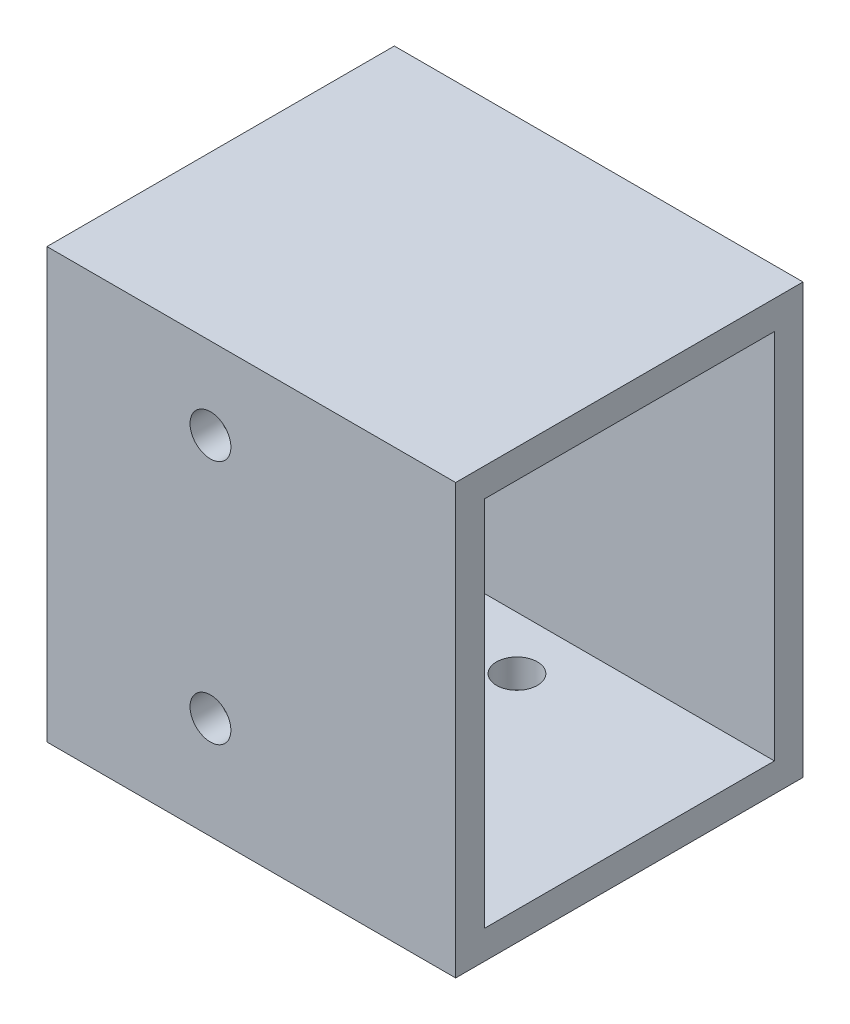
from build123d import *

# Parameters (mm, degrees)
SKETCH1_W                        = 100
SKETCH1_H                        = 85
BOSS_EXTRUDE1_DEPTH              = 105
SKETCH2_W                        = 71
SKETCH2_H                        = 91
CUT_EXTRUDE1_DEPTH               = 90
M10X1_0_TAPPED_HOLE1_D           = 9
M10X1_0_TAPPED_HOLE1_DEPTH       = 23
M10X1_0_TAPPED_HOLE1_CBORE_D     = 10
M10X1_0_TAPPED_HOLE1_CBORE_DEPTH = 20
M10X1_0_TAPPED_HOLE1_TIP         = 2.703872786
M10X1_0_TAPPED_HOLE2_D           = 9
M10X1_0_TAPPED_HOLE2_DEPTH       = 23
M10X1_0_TAPPED_HOLE2_CBORE_D     = 10
M10X1_0_TAPPED_HOLE2_CBORE_DEPTH = 20
M10X1_0_TAPPED_HOLE2_TIP         = 2.703872786
M10X1_0_TAPPED_HOLE3_D           = 9
M10X1_0_TAPPED_HOLE3_DEPTH       = 23
M10X1_0_TAPPED_HOLE3_CBORE_D     = 10
M10X1_0_TAPPED_HOLE3_CBORE_DEPTH = 20
M10X1_0_TAPPED_HOLE3_TIP         = 2.703872786


with BuildPart() as part:
    # Sketch1 → Boss-Extrude1 (new body)
    with BuildSketch(Plane(origin=(0, 0, 0), x_dir=(1, 0, 0), z_dir=(0, 1, 0))):
        with Locations((-11.958288623, 7.903366629)):
            Rectangle(SKETCH1_W, SKETCH1_H)
    extrude(amount=BOSS_EXTRUDE1_DEPTH)

    # Sketch2 → Cut-Extrude1 (cut)
    with BuildSketch(Plane(origin=(38.041711377, 0, 0), x_dir=(0, 0, -1), z_dir=(1, 0, 0))):
        with Locations((7.903366629, 52.5)):
            Rectangle(SKETCH2_W, SKETCH2_H)
    extrude(amount=-CUT_EXTRUDE1_DEPTH, mode=Mode.SUBTRACT)

    # M10x1.0 Tapped Hole1
    with Locations(Plane(origin=(-21.958288623, 85, 34.596633371), x_dir=(1, 0, 0), z_dir=(0, 0, 1))):
        with Locations((0, 0), (0, -60)):
            CounterBoreHole(M10X1_0_TAPPED_HOLE1_D / 2, M10X1_0_TAPPED_HOLE1_CBORE_D / 2, M10X1_0_TAPPED_HOLE1_CBORE_DEPTH, depth=M10X1_0_TAPPED_HOLE1_DEPTH)
            with Locations((0, 0, -(M10X1_0_TAPPED_HOLE1_DEPTH + M10X1_0_TAPPED_HOLE1_TIP / 2))):  # 118° drill point
                Cone(0, M10X1_0_TAPPED_HOLE1_D / 2, M10X1_0_TAPPED_HOLE1_TIP, mode=Mode.SUBTRACT)

    # M10x1.0 Tapped Hole2
    with Locations(Plane(origin=(-11.958288623, 0, -30.403366629), x_dir=(0, 0, -1), z_dir=(0, -1, 0))):
        with Locations((0, 0)):
            CounterBoreHole(M10X1_0_TAPPED_HOLE2_D / 2, M10X1_0_TAPPED_HOLE2_CBORE_D / 2, M10X1_0_TAPPED_HOLE2_CBORE_DEPTH, depth=M10X1_0_TAPPED_HOLE2_DEPTH)
            with Locations((0, 0, -(M10X1_0_TAPPED_HOLE2_DEPTH + M10X1_0_TAPPED_HOLE2_TIP / 2))):  # 118° drill point
                Cone(0, M10X1_0_TAPPED_HOLE2_D / 2, M10X1_0_TAPPED_HOLE2_TIP, mode=Mode.SUBTRACT)

    # M10x1.0 Tapped Hole3
    with Locations(Plane.ZY.offset(61.958288623)):
        with Locations((-7.903366629, 37.5), (-7.903366629, 52.5), (-7.903366629, 67.5)):
            CounterBoreHole(M10X1_0_TAPPED_HOLE3_D / 2, M10X1_0_TAPPED_HOLE3_CBORE_D / 2, M10X1_0_TAPPED_HOLE3_CBORE_DEPTH, depth=M10X1_0_TAPPED_HOLE3_DEPTH)
            with Locations((0, 0, -(M10X1_0_TAPPED_HOLE3_DEPTH + M10X1_0_TAPPED_HOLE3_TIP / 2))):  # 118° drill point
                Cone(0, M10X1_0_TAPPED_HOLE3_D / 2, M10X1_0_TAPPED_HOLE3_TIP, mode=Mode.SUBTRACT)


solid = part.part
